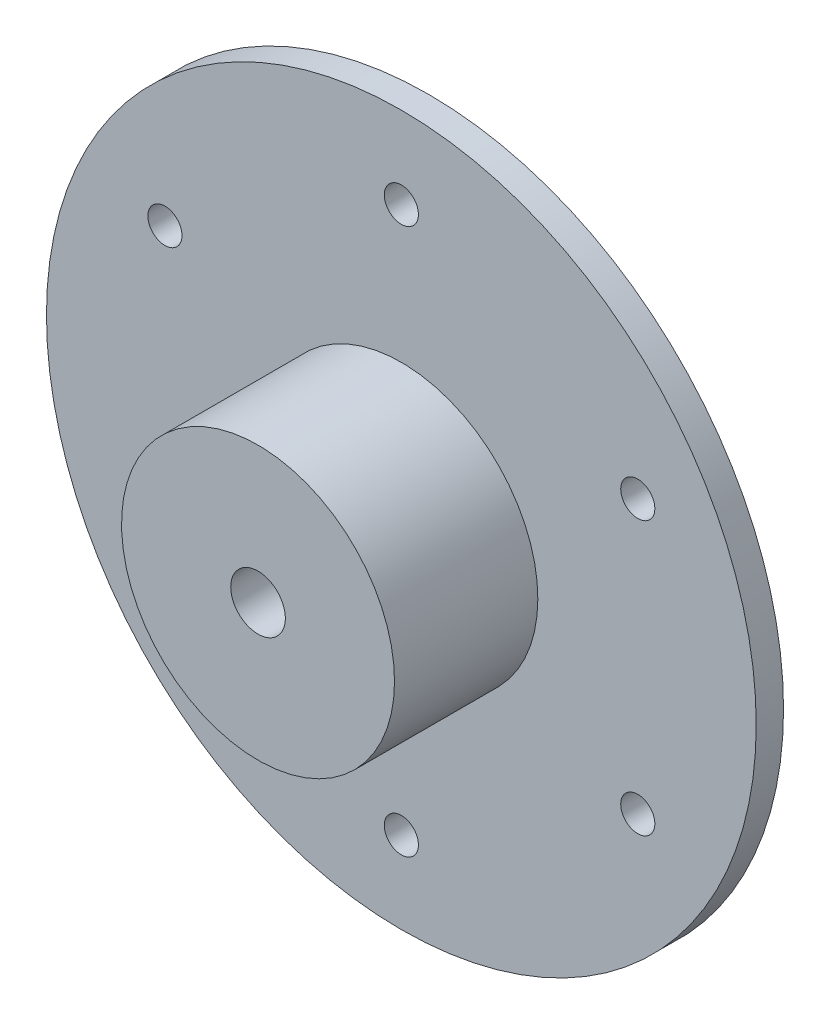
from build123d import *

# Parameters (mm, degrees)
SKETCH2_R               = 20
SKETCH2_R_2             = 4
BOSS_EXTRUDE1_DEPTH     = 21
CUT_EXTRUDE2_REACH      = 79.672
SKETCH3_R               = 2.5
CUT_EXTRUDE3_REACH      = 79.672
CUT_EXTRUDE3_END_RADIUS = 20
SKETCH4_R               = 2


with BuildPart() as part:
    # Sketch1 → Revolve1 (revolve)
    with BuildSketch(Plane(origin=(0, 0, 0), x_dir=(0, 0, -1), z_dir=(1, 0, 0))):
        Polygon((0, 0), (0, 52), (4, 52), (4, 20), (25, 20), (25, 0), align=None)
    revolve(axis=Axis((0, 0, -25), (0, 0, 1)))

    # Sketch2 → Boss-Extrude1 (add)
    with BuildSketch(Plane.XY):
        with Locations(Location((0, 0, 0), (0, 0, 90))):
            Circle(SKETCH2_R)
        with Locations(Location((0, 0, 0), (0, 0, 180))):
            Circle(SKETCH2_R_2, mode=Mode.SUBTRACT)
    extrude(amount=BOSS_EXTRUDE1_DEPTH)

    # Sketch3 → Cut-Extrude2 (cut, up to next)
    with BuildSketch(Plane(origin=(0, 0, -4), x_dir=(-1, 0, 0), z_dir=(0, 0, -1)), mode=Mode.PRIVATE) as cut_extrude2_sk1:
        with Locations(Location((0, 40, 0), (0, 0, 90))):
            Circle(SKETCH3_R)
    cut_extrude2_tool1 = extrude(cut_extrude2_sk1.sketch, amount=-CUT_EXTRUDE2_REACH, mode=Mode.PRIVATE) & part.part
    # Sketch3 → Cut-Extrude2 (cut, up to next)
    with BuildSketch(Plane(origin=(0, 0, -4), x_dir=(-1, 0, 0), z_dir=(0, 0, -1)), mode=Mode.PRIVATE) as cut_extrude2_sk2:
        with Locations(Location((34.641016151, 20, 0), (0, 0, 90))):
            Circle(SKETCH3_R)
    cut_extrude2_tool2 = extrude(cut_extrude2_sk2.sketch, amount=-CUT_EXTRUDE2_REACH, mode=Mode.PRIVATE) & part.part
    # Sketch3 → Cut-Extrude2 (cut, up to next)
    with BuildSketch(Plane(origin=(0, 0, -4), x_dir=(-1, 0, 0), z_dir=(0, 0, -1)), mode=Mode.PRIVATE) as cut_extrude2_sk3:
        with Locations(Location((34.641016151, -20, 0), (0, 0, 90))):
            Circle(SKETCH3_R)
    cut_extrude2_tool3 = extrude(cut_extrude2_sk3.sketch, amount=-CUT_EXTRUDE2_REACH, mode=Mode.PRIVATE) & part.part
    # Sketch3 → Cut-Extrude2 (cut, up to next)
    with BuildSketch(Plane(origin=(0, 0, -4), x_dir=(-1, 0, 0), z_dir=(0, 0, -1)), mode=Mode.PRIVATE) as cut_extrude2_sk4:
        with Locations(Location((0, -40, 0), (0, 0, 90))):
            Circle(SKETCH3_R)
    cut_extrude2_tool4 = extrude(cut_extrude2_sk4.sketch, amount=-CUT_EXTRUDE2_REACH, mode=Mode.PRIVATE) & part.part
    # Sketch3 → Cut-Extrude2 (cut, up to next)
    with BuildSketch(Plane(origin=(0, 0, -4), x_dir=(-1, 0, 0), z_dir=(0, 0, -1)), mode=Mode.PRIVATE) as cut_extrude2_sk5:
        with Locations(Location((-34.641016151, -20, 0), (0, 0, 90))):
            Circle(SKETCH3_R)
    cut_extrude2_tool5 = extrude(cut_extrude2_sk5.sketch, amount=-CUT_EXTRUDE2_REACH, mode=Mode.PRIVATE) & part.part
    # Sketch3 → Cut-Extrude2 (cut, up to next)
    with BuildSketch(Plane(origin=(0, 0, -4), x_dir=(-1, 0, 0), z_dir=(0, 0, -1)), mode=Mode.PRIVATE) as cut_extrude2_sk6:
        with Locations(Location((-34.641016151, 20, 0), (0, 0, 90))):
            Circle(SKETCH3_R)
    cut_extrude2_tool6 = extrude(cut_extrude2_sk6.sketch, amount=-CUT_EXTRUDE2_REACH, mode=Mode.PRIVATE) & part.part
    add(cut_extrude2_tool1.solids().sort_by_distance((0, 40, -4))[0], mode=Mode.SUBTRACT)
    add(cut_extrude2_tool2.solids().sort_by_distance((-34.641016, 20, -4))[0], mode=Mode.SUBTRACT)
    add(cut_extrude2_tool3.solids().sort_by_distance((-34.641016, -20, -4))[0], mode=Mode.SUBTRACT)
    add(cut_extrude2_tool4.solids().sort_by_distance((0, -40, -4))[0], mode=Mode.SUBTRACT)
    add(cut_extrude2_tool5.solids().sort_by_distance((34.641016, -20, -4))[0], mode=Mode.SUBTRACT)
    add(cut_extrude2_tool6.solids().sort_by_distance((34.641016, 20, -4))[0], mode=Mode.SUBTRACT)

    # Cut-Extrude3: up to this cylinder (the profile starts inside it)
    cut_extrude3_end = Plane(origin=(0, 0, 0), z_dir=(0, 0, -1)) * Cylinder(CUT_EXTRUDE3_END_RADIUS, 200.344, mode=Mode.PRIVATE)
    # Sketch4 → Cut-Extrude3 (cut, up to the surface)
    with BuildSketch(Plane(origin=(0, 0, 0), x_dir=(1, 0, 0), z_dir=(0, 1, 0)), mode=Mode.PRIVATE) as cut_extrude3_sk1:
        with Locations(Location((-10, 0, 0), (0, 0, 270))):
            Circle(SKETCH4_R)
    cut_extrude3_tool1 = extrude(cut_extrude3_sk1.sketch, amount=-CUT_EXTRUDE3_REACH, mode=Mode.PRIVATE) & cut_extrude3_end
    add(cut_extrude3_tool1.solids().sort_by_distance((-10, 0, 0))[0], mode=Mode.SUBTRACT)


solid = part.part
